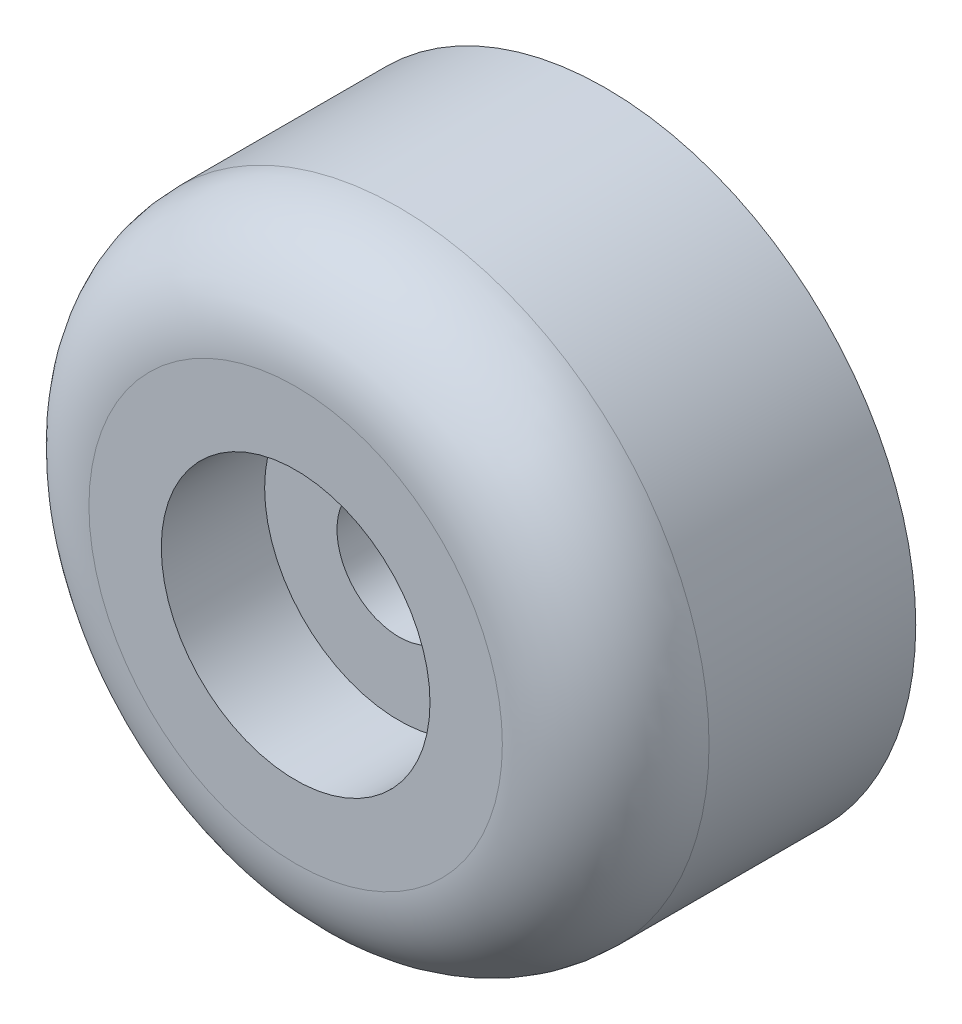
from build123d import *

# Parameters (mm, degrees)
IZIM1_R                     = 15
Y_KSEKLIK_EKSTR_ZYON1_DEPTH = 15
RADYUS1_R                   = 5
IZIM2_R                     = 3
KES_EKSTR_ZYON1_DEPTH       = 15
IZIM3_R                     = 6.5
KES_EKSTR_ZYON2_DEPTH       = 5
RADYUS2_R                   = 0.5


with BuildPart() as part:
    # Çizim1 → Yükseklik-Ekstrüzyon1 (new body)
    with BuildSketch(Plane.XY):
        Circle(IZIM1_R)
    extrude(amount=Y_KSEKLIK_EKSTR_ZYON1_DEPTH)

    # Radyus1
    radyus1_edges = [part.edges().sort_by_distance(p)[0] for p in [
        (-15, 0, 15),
    ]]
    fillet(radyus1_edges, radius=RADYUS1_R)

    # Çizim2 → Kes-Ekstrüzyon1 (cut)
    with BuildSketch(Plane(origin=(0, 0, 0), x_dir=(-1, 0, 0), z_dir=(0, 0, -1))):
        Circle(IZIM2_R)
    extrude(amount=-KES_EKSTR_ZYON1_DEPTH, mode=Mode.SUBTRACT)

    # Çizim3 → Kes-Ekstrüzyon2 (cut)
    with BuildSketch(Plane.XY.offset(15)):
        Circle(IZIM3_R)
    extrude(amount=-KES_EKSTR_ZYON2_DEPTH, mode=Mode.SUBTRACT)

    # Radyus2
    radyus2_edges = [part.edges().sort_by_distance(p)[0] for p in [
        (3, 0, 0),
    ]]
    fillet(radyus2_edges, radius=RADYUS2_R)


solid = part.part
